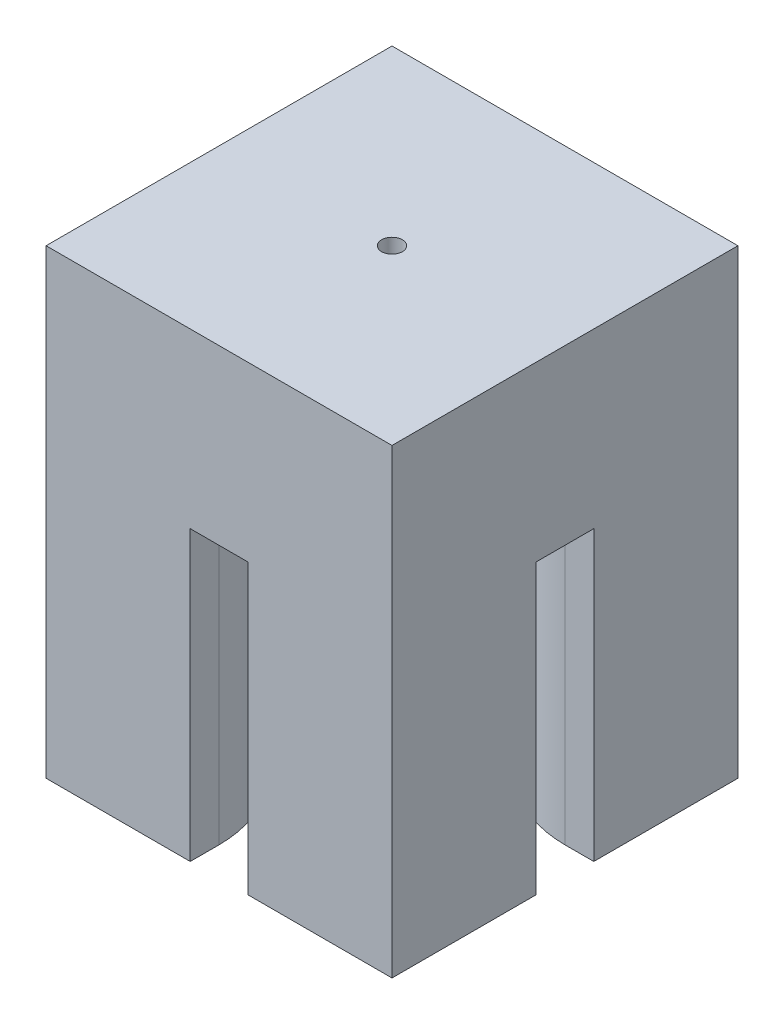
from build123d import *

# Parameters (mm, degrees)
SKETCH1_W           = 30
SKETCH1_H           = 30
BOSS_EXTRUDE1_DEPTH = 40
CUT_EXTRUDE1_REACH  = 42
SKETCH2_R           = 0.9
CUT_EXTRUDE2_REACH  = 32
SKETCH3_W           = 5
SKETCH3_H           = 25
SKETCH4_W           = 5
SKETCH4_H           = 25
CUT_EXTRUDE3_DEPTH  = 30
FILLET1_R           = 10


with BuildPart() as part:
    # Sketch1 → Boss-Extrude1 (new body)
    with BuildSketch(Plane(origin=(0, 0, 0), x_dir=(1, 0, 0), z_dir=(0, 1, 0))):
        Rectangle(SKETCH1_W, SKETCH1_H)
    extrude(amount=BOSS_EXTRUDE1_DEPTH)

    # Sketch2 → Cut-Extrude1 (cut, up to next)
    with BuildSketch(Plane(origin=(0, 40, 0), x_dir=(1, 0, 0), z_dir=(0, 1, 0)), mode=Mode.PRIVATE) as cut_extrude1_sk1:
        Circle(SKETCH2_R)
    cut_extrude1_tool1 = extrude(cut_extrude1_sk1.sketch, amount=-CUT_EXTRUDE1_REACH, mode=Mode.PRIVATE) & part.part
    add(cut_extrude1_tool1.solids().sort_by_distance((0, 40, 0))[0], mode=Mode.SUBTRACT)

    # Sketch3 → Cut-Extrude2 (cut, up to next)
    with BuildSketch(Plane(origin=(0, 0, -15), x_dir=(-1, 0, 0), z_dir=(0, 0, -1)), mode=Mode.PRIVATE) as cut_extrude2_sk1:
        with Locations((0, 12.5)):
            Rectangle(SKETCH3_W, SKETCH3_H)
    cut_extrude2_tool1 = extrude(cut_extrude2_sk1.sketch, amount=-CUT_EXTRUDE2_REACH, mode=Mode.PRIVATE) & part.part
    add(cut_extrude2_tool1.solids().sort_by_distance((0, 12.5, -15))[0], mode=Mode.SUBTRACT)

    # Sketch4 → Cut-Extrude3 (cut)
    with BuildSketch(Plane(origin=(15, 0, 0), x_dir=(0, 0, -1), z_dir=(1, 0, 0))):
        with Locations((0, 12.5)):
            Rectangle(SKETCH4_W, SKETCH4_H)
    extrude(amount=-CUT_EXTRUDE3_DEPTH, mode=Mode.SUBTRACT)

    # Fillet1
    fillet1_edges = [part.edges().sort_by_distance(p)[0] for p in [
        (2.5, 12.5, 2.5),
        (-2.5, 12.5, 2.5),
        (2.5, 12.5, -2.5),
        (-2.5, 12.5, -2.5),
    ]]
    fillet(fillet1_edges, radius=FILLET1_R)


solid = part.part
